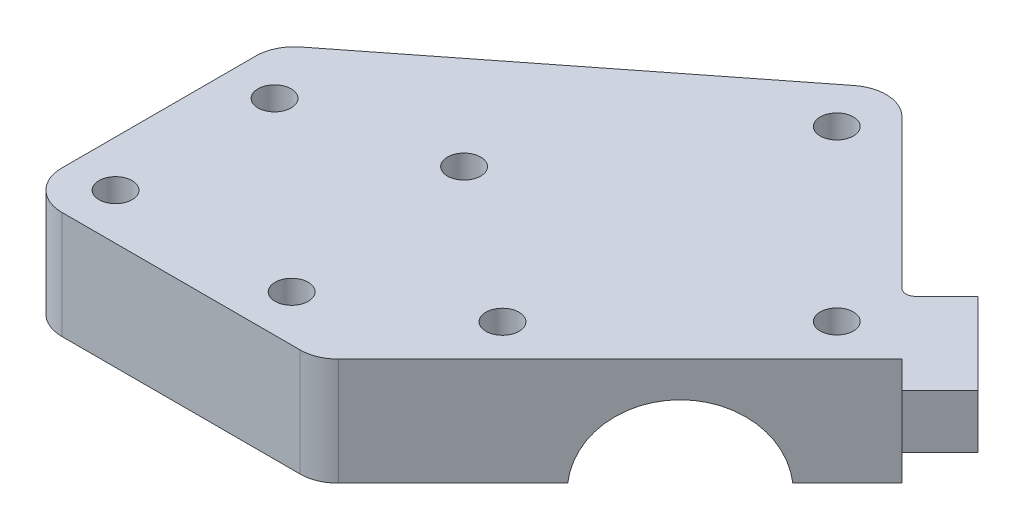
from build123d import *

# Parameters (mm, degrees)
EXTRUDE_1_DEPTH        = 14
EXTRUDE_2_DEPTH        = 7
CUT_EXTRUDE_1_DEPTH    = 38.1
CUT_EXTRUDE_2_DEPTH    = 41.028932188
HOLE_WIZARD_M4_1_D     = 4.318
HOLE_WIZARD_M4_1_DEPTH = 14
FILLET_1_R             = 5
FILLET_3_R             = 1.27
FILLET_4_R             = 1.27


with BuildPart() as part:
    # 草图1 → 凸台-拉伸1 (new body)
    with BuildSketch(Plane.XZ.offset(-1)):
        Polygon((4.743453393, -52.27499012), (35.219755662, -21.79868785), (-2.928932188, 16.35), (-41.028932188, 16.35), (-41.028932188, -16.35), align=None)
    extrude(amount=-EXTRUDE_1_DEPTH)

    # 草图2 → 凸台-拉伸2 (add)
    with BuildSketch(Plane(origin=(0, 15, 0), x_dir=(1, 0, 0), z_dir=(0, 1, 0))):
        Polygon((35.219755662, 21.79868785), (38.755289568, 18.263153944), (43.705037037, 23.212901413), (33.098435319, 33.819503131), (28.14868785, 28.869755662), align=None)
    extrude(amount=-EXTRUDE_2_DEPTH)

    # 草图3 → 切除-拉伸1 (cut)
    with BuildSketch(Plane(origin=(6.710533906, 0, 6.710533906), x_dir=(0.707106781, 0, -0.707106781), z_dir=(0.707106781, 0, 0.707106781))):
        with BuildLine():
            Line((9.538251542, 1), (30.270004579, 1))
            ThreePointArc((30.270004579, 1), (19.904128061, 10.414), (9.538251542, 1))
        make_face()
    extrude(amount=-CUT_EXTRUDE_1_DEPTH, mode=Mode.SUBTRACT)

    # 草图4 → 切除-拉伸2 (cut)
    with BuildSketch(Plane.ZY.offset(41.028932188)):
        with BuildLine():
            Line((-6.270765504, 1), (6.270765504, 1))
            ThreePointArc((6.270765504, 1), (0, 6.35), (-6.270765504, 1))
        make_face()
    extrude(amount=-CUT_EXTRUDE_2_DEPTH, mode=Mode.SUBTRACT)

    # M4 间隙孔1
    with Locations(Plane(origin=(0, 15, 0), x_dir=(1, 0, 0), z_dir=(0, 1, 0))):
        with Locations((-35.028932188, -10.35), (5, 0), (-15, 15), (-12.103043109, -10.35), (-35.028932188, 10.35), (4.743453393, 43.789708745), (26.734474288, 21.79868785)):
            Hole(HOLE_WIZARD_M4_1_D / 2, depth=HOLE_WIZARD_M4_1_DEPTH)

    # 圆角1
    fillet_1_edges = [part.edges().sort_by_distance(p)[0] for p in [
        (-41.028932188, 8, -16.35),
        (-41.028932188, 8, 16.35),
        (-2.928932188, 8, 16.35),
        (4.743453393, 8, -52.27499012),
    ]]
    fillet(fillet_1_edges, radius=FILLET_1_R)

    # 圆角3
    fillet_3_edges = [part.edges().sort_by_distance(p)[0] for p in [
        (28.14868785, 11.5, -28.869755662),
    ]]
    fillet(fillet_3_edges, radius=FILLET_3_R)

    # 圆角4
    fillet_4_edges = [part.edges().sort_by_distance(p)[0] for p in [
        (31.684221756, 8, -25.334221756),
    ]]
    fillet(fillet_4_edges, radius=FILLET_4_R)


solid = part.part
